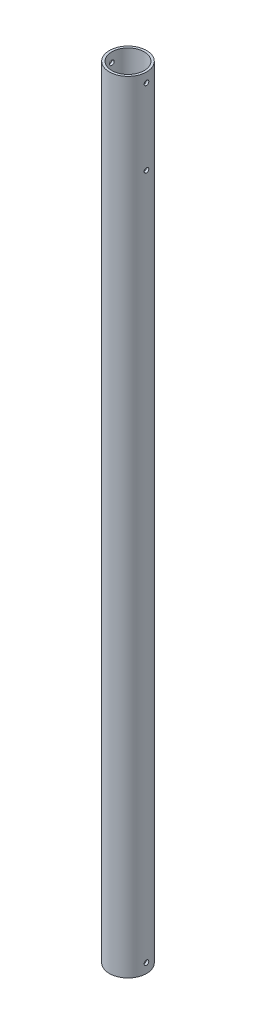
from build123d import *

# Parameters (mm, degrees)
SKETCH1_R               = 24.97201
SKETCH1_R_2             = 21.79701
BOSS_EXTRUDE1_DEPTH     = 1047.75
SKETCH2_R               = 3.1115
CUT_EXTRUDE1_DEPTH      = 25.97201
SKETCH3_R               = 3.1115
CUT_EXTRUDE3_DEPTH      = 25.9720101
CUT_EXTRUDE3_DEPTH_BACK = 25.9720101


with BuildPart() as part:
    # Sketch1 → Boss-Extrude1 (new body)
    with BuildSketch(Plane(origin=(0, 0, 0), x_dir=(1, 0, 0), z_dir=(0, 1, 0))):
        Circle(SKETCH1_R)
        Circle(SKETCH1_R_2, mode=Mode.SUBTRACT)
    extrude(amount=BOSS_EXTRUDE1_DEPTH)

    # Sketch2 → Cut-Extrude1 (cut, symmetric)
    with BuildSketch(Plane(origin=(0, 0, 0), x_dir=(0, 0, -1), z_dir=(1, 0, 0))):
        with Locations((0, 12.7)):
            Circle(SKETCH2_R)
    cut_extrude1 = extrude(amount=CUT_EXTRUDE1_DEPTH, both=True, mode=Mode.SUBTRACT)

    # Mirror1: Cut-Extrude1 across plane
    add(cut_extrude1.mirror(Plane.ZX.offset(523.875)), mode=Mode.SUBTRACT)

    # Sketch3 → Cut-Extrude3 (cut, two sides)
    with BuildSketch(Plane(origin=(0, 0, 0), x_dir=(0, 0, -1), z_dir=(1, 0, 0))) as cut_extrude3_sk:
        with Locations((0, 933.45)):
            Circle(SKETCH3_R)
    extrude(amount=CUT_EXTRUDE3_DEPTH, mode=Mode.SUBTRACT)
    extrude(cut_extrude3_sk.sketch, amount=-CUT_EXTRUDE3_DEPTH_BACK, mode=Mode.SUBTRACT)


solid = part.part
